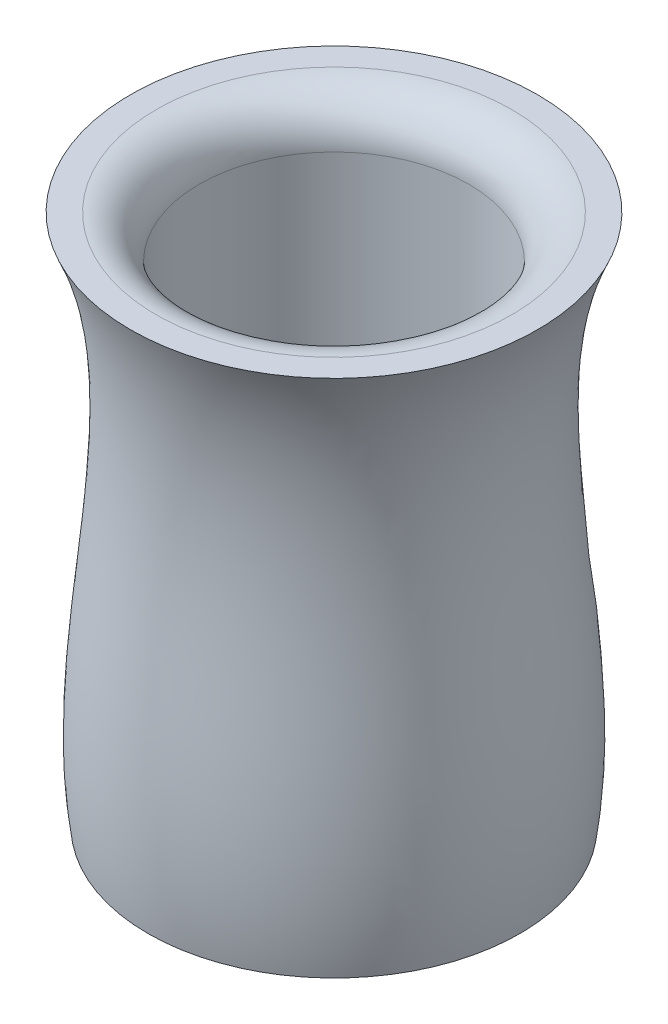
from build123d import *

# Parameters (mm, degrees)
SKETCH2_R          = 31.253383714
CUT_EXTRUDE1_DEPTH = 117
FILLET1_R          = 10


with BuildPart() as part:
    # Sketch1 → Revolve1 (revolve)
    with BuildSketch(Plane.XY):
        with BuildLine():
            Line((0, -41.943209239), (43.16485611, -41.943209239))
            add(Edge.make_bspline(
                [(43.16485611, -41.943209239), (49.298367105, -1.238999909), (30.381887642, 43.902165166), (47.237012347, 81.443124736)],
                knots=[0, 0, 0, 0, 1, 1, 1, 1], degree=3))
            Line((47.237012347, 81.443124736), (0, 81.443124736))
            Line((0, 81.443124736), (0, -41.943209239))
        make_face()
    revolve(axis=Axis((0, 86.736927844, 0), (0, -1, 0)))

    # Sketch2 → Cut-Extrude1 (cut)
    with BuildSketch(Plane(origin=(0, 81.443124736, 0), x_dir=(1, 0, 0), z_dir=(0, 1, 0))):
        Circle(SKETCH2_R)
    extrude(amount=-CUT_EXTRUDE1_DEPTH, mode=Mode.SUBTRACT)

    # Fillet1
    fillet1_edges = [part.edges().sort_by_distance(p)[0] for p in [
        (-31.253383714, 81.443124736, 0),
    ]]
    fillet(fillet1_edges, radius=FILLET1_R)


solid = part.part
